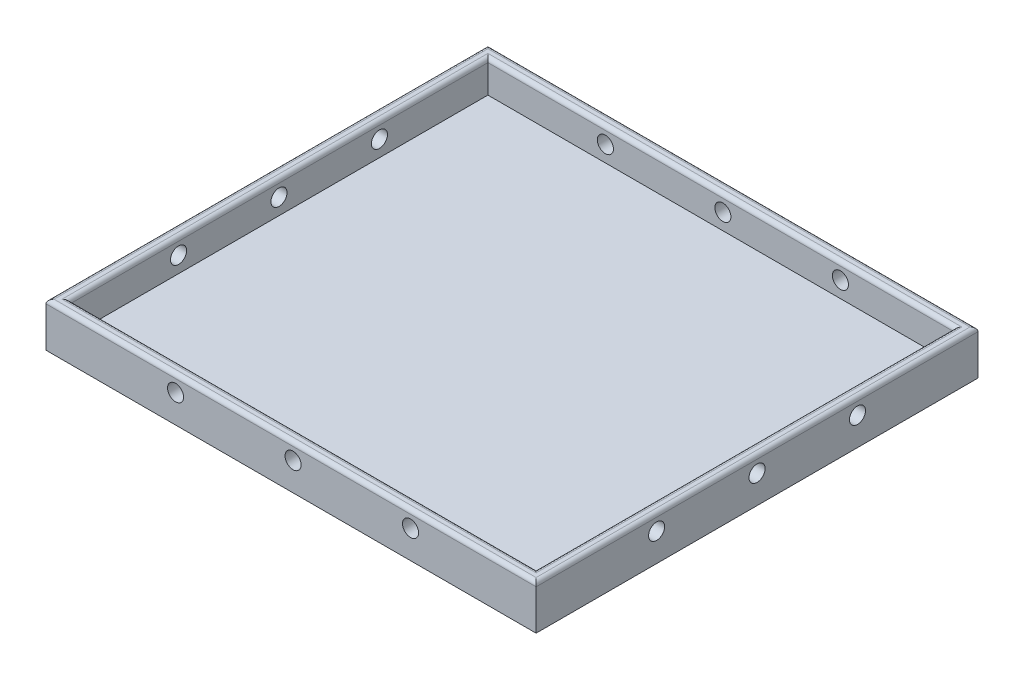
from build123d import *

# Parameters (mm, degrees)
SKETCH1_W               = 122
SKETCH1_H               = 110
BOSS_EXTRUDE1_DEPTH     = 11
SKETCH4_W               = 116
SKETCH4_H               = 104
CUT_EXTRUDE1_DEPTH      = 8
SKETCH6_R               = 1.999999993
SKETCH6_R_2             = 2
CUT_EXTRUDE6_DEPTH      = 120
CUT_EXTRUDE6_DEPTH_BACK = 4
SKETCH5_R               = 2
CUT_EXTRUDE5_DEPTH      = 108
CUT_EXTRUDE5_DEPTH_BACK = 4
FILLET2_R               = 1


with BuildPart() as part:
    # Sketch1 → Boss-Extrude1 (new body)
    with BuildSketch(Plane(origin=(0, 0, 0), x_dir=(1, 0, 0), z_dir=(0, 1, 0))):
        with Locations((-140.609907121, 22.894736842)):
            Rectangle(SKETCH1_W, SKETCH1_H)
    extrude(amount=BOSS_EXTRUDE1_DEPTH)

    # Sketch4 → Cut-Extrude1 (cut)
    with BuildSketch(Plane(origin=(0, 11, 0), x_dir=(1, 0, 0), z_dir=(0, 1, 0))):
        with Locations((-140.609907121, 22.894736842)):
            Rectangle(SKETCH4_W, SKETCH4_H)
    extrude(amount=-CUT_EXTRUDE1_DEPTH, mode=Mode.SUBTRACT)

    # Sketch6 → Cut-Extrude6 (cut, two sides)
    with BuildSketch(Plane(origin=(-198.609907121, 0, 0), x_dir=(0, 0, -1), z_dir=(1, 0, 0))) as cut_extrude6_sk:
        with Locations((-2.105263158, 6.999999977)):
            Circle(SKETCH6_R)
        with Locations((22.894736842, 6.999999977)):
            Circle(SKETCH6_R)
        with Locations((47.894736842, 7)):
            Circle(SKETCH6_R_2)
    extrude(amount=CUT_EXTRUDE6_DEPTH, mode=Mode.SUBTRACT)
    extrude(cut_extrude6_sk.sketch, amount=-CUT_EXTRUDE6_DEPTH_BACK, mode=Mode.SUBTRACT)

    # Sketch5 → Cut-Extrude5 (cut, two sides)
    with BuildSketch(Plane.XY.offset(-74.894736842)) as cut_extrude5_sk:
        with Locations((-169.359907121, 7)):
            Circle(SKETCH5_R)
        with Locations((-140.109907121, 7)):
            Circle(SKETCH5_R)
        with Locations((-110.859907121, 7)):
            Circle(SKETCH5_R)
    extrude(amount=CUT_EXTRUDE5_DEPTH, mode=Mode.SUBTRACT)
    extrude(cut_extrude5_sk.sketch, amount=-CUT_EXTRUDE5_DEPTH_BACK, mode=Mode.SUBTRACT)

    # Fillet2
    fillet2_edges = [part.edges().sort_by_distance(p)[0] for p in [
        (-79.609907121, 11, -22.894736842),
        (-140.609907121, 11, -77.894736842),
        (-198.609907121, 11, -22.894736842),
        (-140.609907121, 11, 29.105263158),
        (-82.609907121, 11, -22.894736842),
        (-140.609907121, 11, -74.894736842),
        (-201.609907121, 11, -22.894736842),
        (-140.609907121, 11, 32.105263158),
    ]]
    fillet(fillet2_edges, radius=FILLET2_R)


solid = part.part
